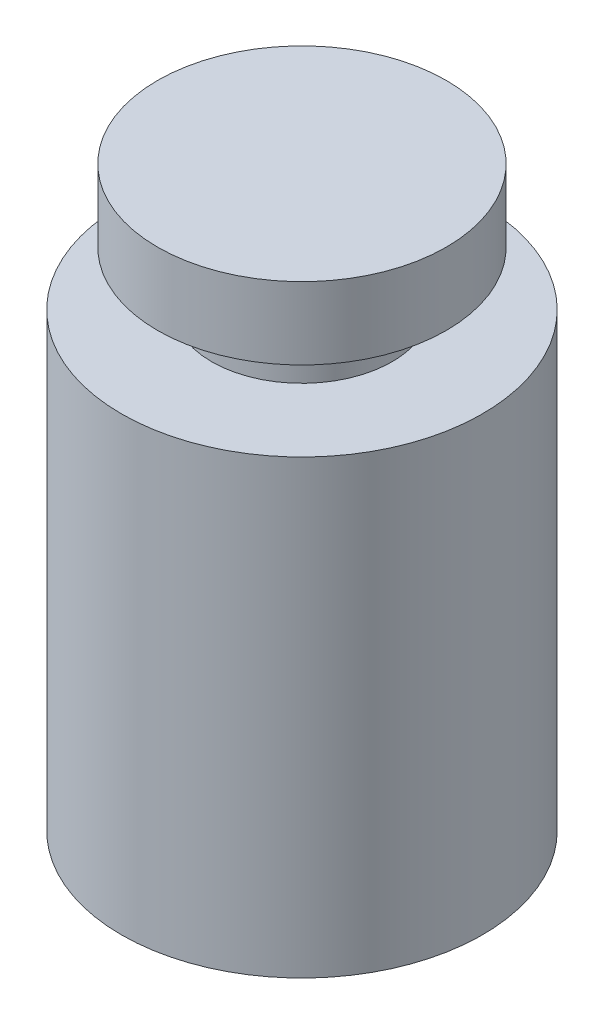
from build123d import *


with BuildPart() as part:
    # Schizzo1 → Rivoluzione1 (revolve)
    with BuildSketch(Plane.XY):
        Polygon((0, 0), (-10, 0), (-10, 25), (-5, 25), (-5, 28), (-8, 28), (-8, 32), (0, 32), align=None)
    revolve(axis=Axis((0, 43.867924528, 0), (0, -1, 0)))


solid = part.part
